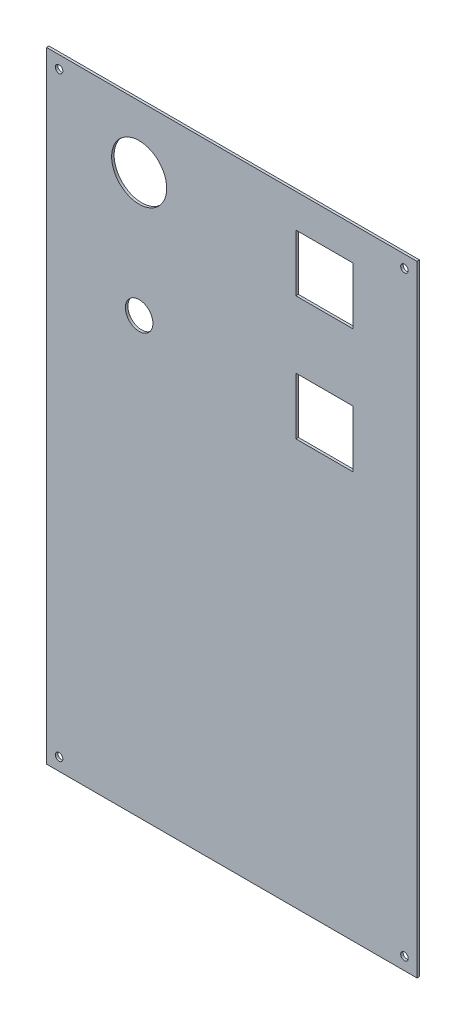
from build123d import *

# Parameters (mm, degrees)
SKETCH1_W           = 296
SKETCH1_H           = 496
SKETCH1_R           = 11
SKETCH1_R_2         = 22
SKETCH1_R_3         = 3
SKETCH1_W_2         = 45.5
SKETCH1_H_2         = 45.5
BOSS_EXTRUDE1_DEPTH = 2


with BuildPart() as part:
    # Sketch1 → Boss-Extrude1 (new body)
    with BuildSketch(Plane.XY):
        Rectangle(SKETCH1_W, SKETCH1_H)
        with Locations((-74, 99.5)):
            Circle(SKETCH1_R, mode=Mode.SUBTRACT)
        with Locations((-74, 198.5)):
            Circle(SKETCH1_R_2, mode=Mode.SUBTRACT)
        with Locations((-138, 238)):
            Circle(SKETCH1_R_3, mode=Mode.SUBTRACT)
        with Locations((138, 238)):
            Circle(SKETCH1_R_3, mode=Mode.SUBTRACT)
        with Locations((-138, -238)):
            Circle(SKETCH1_R_3, mode=Mode.SUBTRACT)
        with Locations((138, -238)):
            Circle(SKETCH1_R_3, mode=Mode.SUBTRACT)
        with Locations((74, 198.5)):
            Rectangle(SKETCH1_W_2, SKETCH1_H_2, mode=Mode.SUBTRACT)
        with Locations((74, 99.5)):
            Rectangle(SKETCH1_W_2, SKETCH1_H_2, mode=Mode.SUBTRACT)
    extrude(amount=BOSS_EXTRUDE1_DEPTH)


solid = part.part
